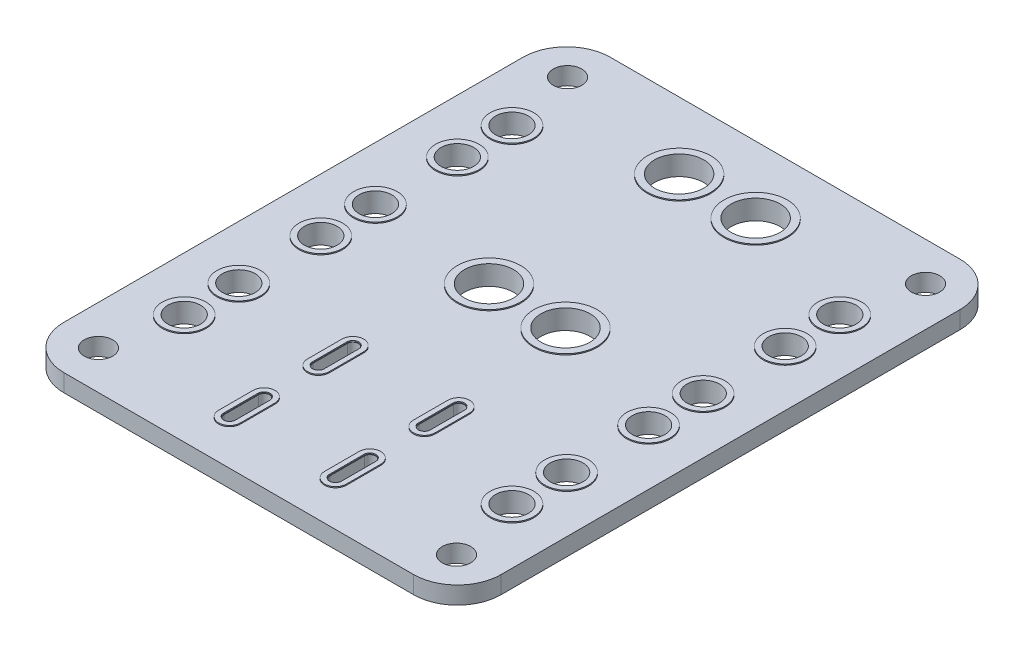
from build123d import *

# Parameters (mm, degrees)
SALIENTE_EXTRUIR1_DEPTH    = 0.8
CROQUIS2_R                 = 1.3
CORTAR_EXTRUIR1_DEPTH      = 1
CORTAR_EXTRUIR1_DEPTH_BACK = 2.6
CROQUIS6_R                 = 2.25
CROQUIS6_R_2               = 1.5
CORTAR_EXTRUIR3_DEPTH      = 2.6
CROQUIS7_R                 = 2
CROQUIS7_R_2               = 1.5
CROQUIS7_R_3               = 2.894896359
CROQUIS7_R_4               = 2.25
SALIENTE_EXTRUIR3_DEPTH    = 0.9


with BuildPart() as part:
    # Croquis1 → Saliente-Extruir1 (new body, symmetric)
    with BuildSketch(Plane(origin=(0, 0, 0), x_dir=(1, 0, 0), z_dir=(0, 1, 0))):
        with BuildLine():
            Line((-16, 25), (16, 25))
            ThreePointArc((16, 25), (18.828427125, 23.828427125), (20, 21))
            Line((20, 21), (20, -21))
            ThreePointArc((20, -21), (18.828427125, -23.828427125), (16, -25))
            Line((16, -25), (-16, -25))
            ThreePointArc((-16, -25), (-18.828427125, -23.828427125), (-20, -21))
            Line((-20, -21), (-20, 21))
            ThreePointArc((-20, 21), (-18.828427125, 23.828427125), (-16, 25))
        make_face()
    extrude(amount=SALIENTE_EXTRUIR1_DEPTH, both=True)

    # Croquis2 → Cortar-Extruir1 (cut, two sides)
    with BuildSketch(Plane(origin=(0, 0.8, 0), x_dir=(1, 0, 0), z_dir=(0, 1, 0))) as cortar_extruir1_sk:
        with Locations((-16.383, 21.463)):
            Circle(CROQUIS2_R)
        with Locations((16.383, 21.463)):
            Circle(CROQUIS2_R)
        with Locations((16.383, -21.463)):
            Circle(CROQUIS2_R)
        with Locations((-16.383, -21.463)):
            Circle(CROQUIS2_R)
    extrude(amount=CORTAR_EXTRUIR1_DEPTH, mode=Mode.SUBTRACT)
    extrude(cortar_extruir1_sk.sketch, amount=-CORTAR_EXTRUIR1_DEPTH_BACK, mode=Mode.SUBTRACT)

    # Croquis6 → Cortar-Extruir3 (cut, through all)
    with BuildSketch(Plane(origin=(0, 0.8, 0), x_dir=(1, 0, 0), z_dir=(0, 1, 0))):
        with Locations((-3.5, 18.796)):
            Circle(CROQUIS6_R)
        with Locations((3.5, 18.796)):
            Circle(CROQUIS6_R)
        with Locations((-15, 2.5)):
            Circle(CROQUIS6_R_2)
        with Locations((-15, -2.5)):
            Circle(CROQUIS6_R_2)
        with Locations((-15, 10)):
            Circle(CROQUIS6_R_2)
        with Locations((-15, 15)):
            Circle(CROQUIS6_R_2)
        with Locations((-15, -10)):
            Circle(CROQUIS6_R_2)
        with Locations((-15, -15)):
            Circle(CROQUIS6_R_2)
        with Locations((15, -15)):
            Circle(CROQUIS6_R_2)
        with Locations((15, -10)):
            Circle(CROQUIS6_R_2)
        with Locations((15, 15)):
            Circle(CROQUIS6_R_2)
        with Locations((15, 10)):
            Circle(CROQUIS6_R_2)
        with Locations((15, -2.5)):
            Circle(CROQUIS6_R_2)
        with Locations((15, 2.5)):
            Circle(CROQUIS6_R_2)
        with Locations((3.5, 1.397)):
            Circle(CROQUIS6_R)
        with Locations((-3.5, 1.397)):
            Circle(CROQUIS6_R)
        with BuildLine():
            Line((5.347, -9.721), (5.347, -12.871))
            ThreePointArc((5.347, -12.871), (4.847, -13.371), (4.347, -12.871))
            Line((4.347, -12.871), (4.347, -9.721))
            ThreePointArc((4.347, -9.721), (4.847, -9.221), (5.347, -9.721))
        make_face()
        with BuildLine():
            Line((-5.347, -9.721), (-5.347, -12.871))
            ThreePointArc((-5.347, -12.871), (-4.847, -13.371), (-4.347, -12.871))
            Line((-4.347, -12.871), (-4.347, -9.721))
            ThreePointArc((-4.347, -9.721), (-4.847, -9.221), (-5.347, -9.721))
        make_face()
        with BuildLine():
            Line((5.347, -20.999), (5.347, -17.849))
            ThreePointArc((5.347, -17.849), (4.847, -17.349), (4.347, -17.849))
            Line((4.347, -17.849), (4.347, -20.999))
            ThreePointArc((4.347, -20.999), (4.847, -21.499), (5.347, -20.999))
        make_face()
        with BuildLine():
            Line((-5.347, -20.999), (-5.347, -17.849))
            ThreePointArc((-5.347, -17.849), (-4.847, -17.349), (-4.347, -17.849))
            Line((-4.347, -17.849), (-4.347, -20.999))
            ThreePointArc((-4.347, -20.999), (-4.847, -21.499), (-5.347, -20.999))
        make_face()
    extrude(amount=-CORTAR_EXTRUIR3_DEPTH, mode=Mode.SUBTRACT)

    # Croquis7 → Saliente-Extruir3 (add, symmetric)
    with BuildSketch(Plane(origin=(0, 0, 0), x_dir=(1, 0, 0), z_dir=(0, 1, 0))):
        with Locations((-15, 15)):
            Circle(CROQUIS7_R)
        with Locations((-15, 15)):
            Circle(CROQUIS7_R_2, mode=Mode.SUBTRACT)
        with Locations((-15, 10)):
            Circle(CROQUIS7_R)
        with Locations((-15, 10)):
            Circle(CROQUIS7_R_2, mode=Mode.SUBTRACT)
        with Locations((-15, 2.5)):
            Circle(CROQUIS7_R)
        with Locations((-15, 2.5)):
            Circle(CROQUIS7_R_2, mode=Mode.SUBTRACT)
        with Locations((-15, -2.5)):
            Circle(CROQUIS7_R)
        with Locations((-15, -2.5)):
            Circle(CROQUIS7_R_2, mode=Mode.SUBTRACT)
        with Locations((-15, -15)):
            Circle(CROQUIS7_R)
        with Locations((-15, -15)):
            Circle(CROQUIS7_R_2, mode=Mode.SUBTRACT)
        with Locations((-15, -10)):
            Circle(CROQUIS7_R)
        with Locations((-15, -10)):
            Circle(CROQUIS7_R_2, mode=Mode.SUBTRACT)
        with Locations((-3.5, 18.796)):
            Circle(CROQUIS7_R_3)
        with Locations((-3.5, 18.796)):
            Circle(CROQUIS7_R_4, mode=Mode.SUBTRACT)
        with Locations((3.5, 18.796)):
            Circle(CROQUIS7_R_3)
        with Locations((3.5, 18.796)):
            Circle(CROQUIS7_R_4, mode=Mode.SUBTRACT)
        with Locations((15, -10)):
            Circle(CROQUIS7_R)
        with Locations((15, -10)):
            Circle(CROQUIS7_R_2, mode=Mode.SUBTRACT)
        with Locations((15, -15)):
            Circle(CROQUIS7_R)
        with Locations((15, -15)):
            Circle(CROQUIS7_R_2, mode=Mode.SUBTRACT)
        with Locations((15, -2.5)):
            Circle(CROQUIS7_R)
        with Locations((15, -2.5)):
            Circle(CROQUIS7_R_2, mode=Mode.SUBTRACT)
        with Locations((15, 2.5)):
            Circle(CROQUIS7_R)
        with Locations((15, 2.5)):
            Circle(CROQUIS7_R_2, mode=Mode.SUBTRACT)
        with Locations((15, 10)):
            Circle(CROQUIS7_R)
        with Locations((15, 10)):
            Circle(CROQUIS7_R_2, mode=Mode.SUBTRACT)
        with Locations((15, 15)):
            Circle(CROQUIS7_R)
        with Locations((15, 15)):
            Circle(CROQUIS7_R_2, mode=Mode.SUBTRACT)
        with Locations((3.5, 1.397)):
            Circle(CROQUIS7_R_3)
        with Locations((3.5, 1.397)):
            Circle(CROQUIS7_R_4, mode=Mode.SUBTRACT)
        with Locations((-3.5, 1.397)):
            Circle(CROQUIS7_R_3)
        with Locations((-3.5, 1.397)):
            Circle(CROQUIS7_R_4, mode=Mode.SUBTRACT)
        with BuildLine():
            Line((-3.847, -12.871), (-3.847, -9.721))
            ThreePointArc((-3.847, -9.721), (-4.847, -8.721), (-5.847, -9.721))
            Line((-5.847, -9.721), (-5.847, -12.871))
            ThreePointArc((-5.847, -12.871), (-4.847, -13.871), (-3.847, -12.871))
        make_face()
        with BuildLine():
            Line((-4.297, -12.871), (-4.297, -9.721))
            ThreePointArc((-4.297, -9.721), (-4.847, -9.171), (-5.397, -9.721))
            Line((-5.397, -9.721), (-5.397, -12.871))
            ThreePointArc((-5.397, -12.871), (-4.847, -13.421), (-4.297, -12.871))
        make_face(mode=Mode.SUBTRACT)
        with BuildLine():
            Line((5.847, -12.871), (5.847, -9.721))
            ThreePointArc((5.847, -9.721), (4.847, -8.721), (3.847, -9.721))
            Line((3.847, -9.721), (3.847, -12.871))
            ThreePointArc((3.847, -12.871), (4.847, -13.871), (5.847, -12.871))
        make_face()
        with BuildLine():
            Line((5.397, -12.871), (5.397, -9.721))
            ThreePointArc((5.397, -9.721), (4.847, -9.171), (4.297, -9.721))
            Line((4.297, -9.721), (4.297, -12.871))
            ThreePointArc((4.297, -12.871), (4.847, -13.421), (5.397, -12.871))
        make_face(mode=Mode.SUBTRACT)
        with BuildLine():
            Line((-5.847, -17.849), (-5.847, -20.999))
            ThreePointArc((-5.847, -20.999), (-4.847, -21.999), (-3.847, -20.999))
            Line((-3.847, -20.999), (-3.847, -17.849))
            ThreePointArc((-3.847, -17.849), (-4.847, -16.849), (-5.847, -17.849))
        make_face()
        with BuildLine():
            Line((-4.297, -20.999), (-4.297, -17.849))
            ThreePointArc((-4.297, -17.849), (-4.847, -17.299), (-5.397, -17.849))
            Line((-5.397, -17.849), (-5.397, -20.999))
            ThreePointArc((-5.397, -20.999), (-4.847, -21.549), (-4.297, -20.999))
        make_face(mode=Mode.SUBTRACT)
        with BuildLine():
            Line((5.847, -20.999), (5.847, -17.849))
            ThreePointArc((5.847, -17.849), (4.847, -16.849), (3.847, -17.849))
            Line((3.847, -17.849), (3.847, -20.999))
            ThreePointArc((3.847, -20.999), (4.847, -21.999), (5.847, -20.999))
        make_face()
        with BuildLine():
            Line((5.397, -20.999), (5.397, -17.849))
            ThreePointArc((5.397, -17.849), (4.847, -17.299), (4.297, -17.849))
            Line((4.297, -17.849), (4.297, -20.999))
            ThreePointArc((4.297, -20.999), (4.847, -21.549), (5.397, -20.999))
        make_face(mode=Mode.SUBTRACT)
    extrude(amount=SALIENTE_EXTRUIR3_DEPTH, both=True)


solid = part.part
